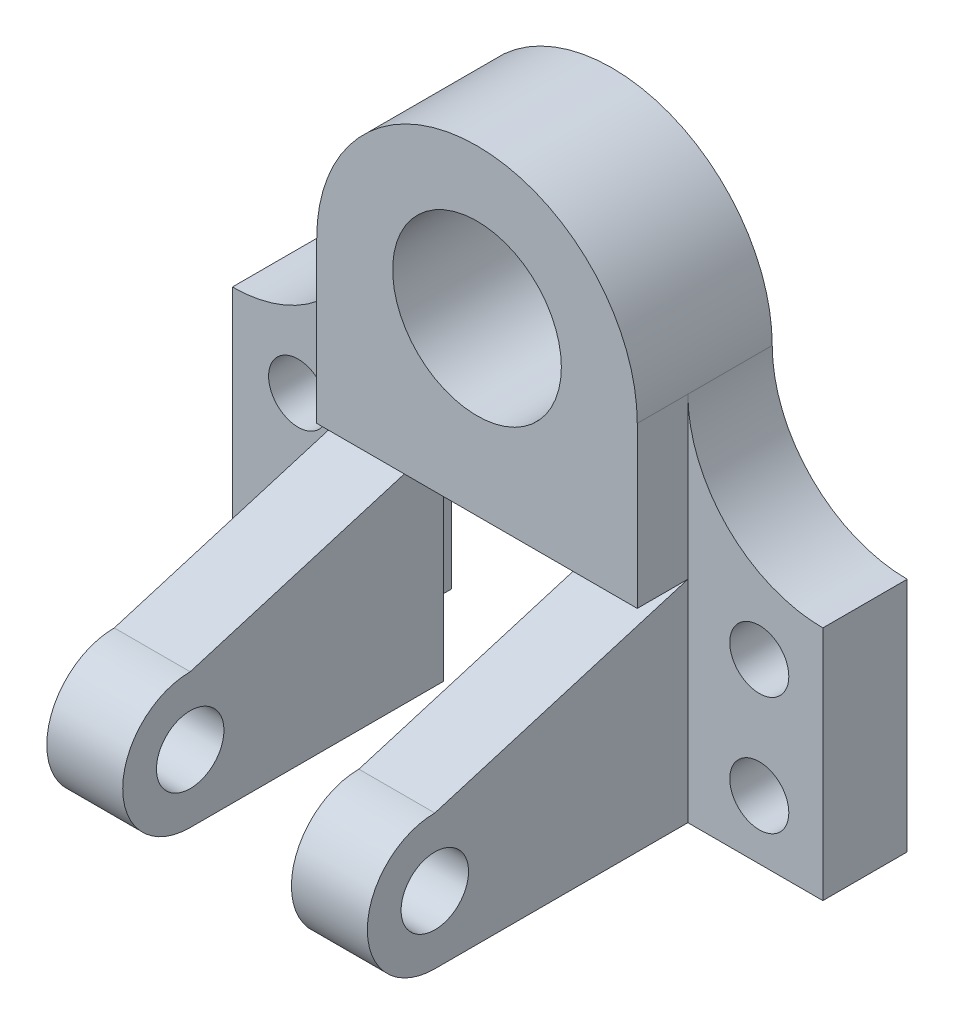
from build123d import *

# Parameters (mm, degrees)
BOSS_EXTRUDE1_DEPTH = 32
BOSS_EXTRUDE2_DEPTH = 20
SKETCH2_R           = 7
CUT_EXTRUDE1_DEPTH  = 20
SKETCH3_R           = 20
CUT_EXTRUDE3_DEPTH  = 109.166538264
BOSS_EXTRUDE3_DEPTH = 18
BOSS_EXTRUDE4_DEPTH = 18
SKETCH6_R           = 8
CUT_EXTRUDE4_DEPTH  = 164.266653056


with BuildPart() as part:
    # Sketch1 → Boss-Extrude1 (new body)
    with BuildSketch(Plane.XY):
        with BuildLine():
            Line((-38, 38), (-38, 0))
            Line((-38, 0), (38, 0))
            Line((38, 0), (38, 38))
            ThreePointArc((38, 38), (0, 76), (-38, 38))
        make_face()
    extrude(amount=BOSS_EXTRUDE1_DEPTH)

    # Sketch1_3 → Boss-Extrude2 (add)
    with BuildSketch(Plane.XY):
        with BuildLine():
            Line((-38, -50), (-38, 38))
            ThreePointArc((-38, 38), (-47.372583002, 15.372583002), (-70, 6))
            Line((-70, 6), (-70, -50))
            Line((-70, -50), (-38, -50))
        make_face()
        with BuildLine():
            Line((38, 38), (38, -50))
            Line((38, -50), (70, -50))
            Line((70, -50), (70, 6))
            ThreePointArc((70, 6), (47.372583002, 15.372583002), (38, 38))
        make_face()
    extrude(amount=BOSS_EXTRUDE2_DEPTH)

    # Sketch2 → Cut-Extrude1 (cut)
    with BuildSketch(Plane.XY.offset(20)):
        with Locations((-54.414414875, -8)):
            Circle(SKETCH2_R)
        with Locations((-54.414414875, -36)):
            Circle(SKETCH2_R)
        with Locations((54.929377791, -8)):
            Circle(SKETCH2_R)
        with Locations((54.929377791, -36)):
            Circle(SKETCH2_R)
    extrude(amount=-CUT_EXTRUDE1_DEPTH, mode=Mode.SUBTRACT)

    # Sketch3 → Cut-Extrude3 (cut, through all)
    with BuildSketch(Plane.XY.offset(32)):
        with Locations((0, 40.550516049)):
            Circle(SKETCH3_R)
    extrude(amount=-CUT_EXTRUDE3_DEPTH, mode=Mode.SUBTRACT)


with BuildPart() as body_2:
    # Sketch4 → Boss-Extrude3 (new body)
    with BuildSketch(Plane(origin=(-38, 0, 0), x_dir=(0, 0, -1), z_dir=(1, 0, 0))):
        with BuildLine():
            Line((-20, -50), (-80, -50))
            ThreePointArc((-80, -50), (-96, -34), (-80, -18))
            Line((-80, -18), (-20, 0))
            Line((-20, 0), (-20, -50))
        make_face()
    extrude(amount=BOSS_EXTRUDE3_DEPTH)


with BuildPart() as body_3:
    # Sketch5 → Boss-Extrude4 (new body)
    with BuildSketch(Plane.ZY.offset(-38)):
        with BuildLine():
            Line((20, -50), (80, -50))
            ThreePointArc((80, -50), (96, -34), (80, -18))
            Line((80, -18), (20, 0))
            Line((20, 0), (20, -50))
        make_face()
    extrude(amount=BOSS_EXTRUDE4_DEPTH)


with BuildPart() as cut_extrude4_tool:
    # Sketch6 → Cut-Extrude4 (new, through all)
    with BuildSketch(Plane.ZY.offset(38)):
        with Locations((80, -33.999616417)):
            Circle(SKETCH6_R)
    extrude(amount=-CUT_EXTRUDE4_DEPTH)


with BuildPart() as body_2_1:
    add(body_2.part)

    # Cut-Extrude4: cut by cut_extrude4_tool
    add(cut_extrude4_tool.part, mode=Mode.SUBTRACT)


with BuildPart() as body_3_1:
    add(body_3.part)

    # Cut-Extrude4: cut by cut_extrude4_tool
    add(cut_extrude4_tool.part, mode=Mode.SUBTRACT)


solid = Compound([part.part, body_2_1.part, body_3_1.part])
